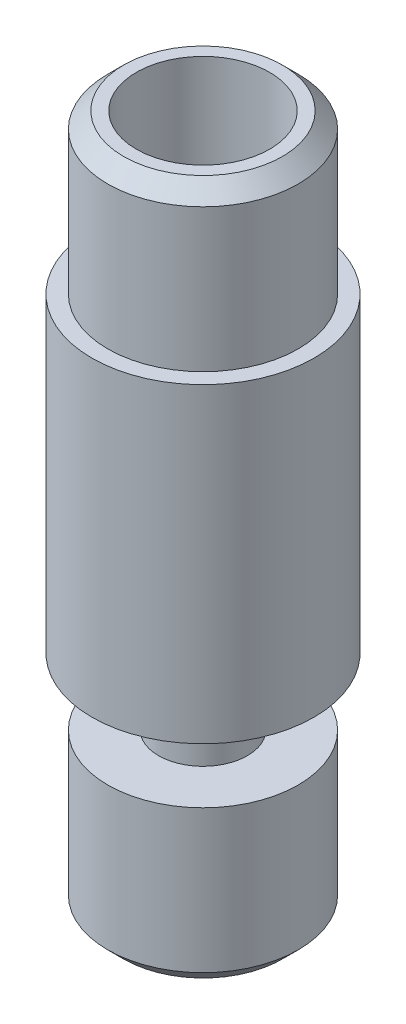
from build123d import *


with BuildPart() as part:
    # Sketch1 → Revolve1 (revolve)
    with BuildSketch(Plane(origin=(0, 0, 0), x_dir=(-1, 0, 0), z_dir=(0, 0, -1))):
        Polygon((-2.5, 0), (-1, 0), (-1, 15.8), (-2.1, 16.9), (-2.1, 21.9), (-2.5, 21.9), (-3, 21.4), (-3, 16.9), (-3.5, 16.9), (-3.5, 7.1), (-1.4, 7.1), (-1.4, 5), (-3, 5), (-3, 0.5), align=None)
    revolve(axis=Axis((0, 0, 0), (0, 1, 0)))


solid = part.part
